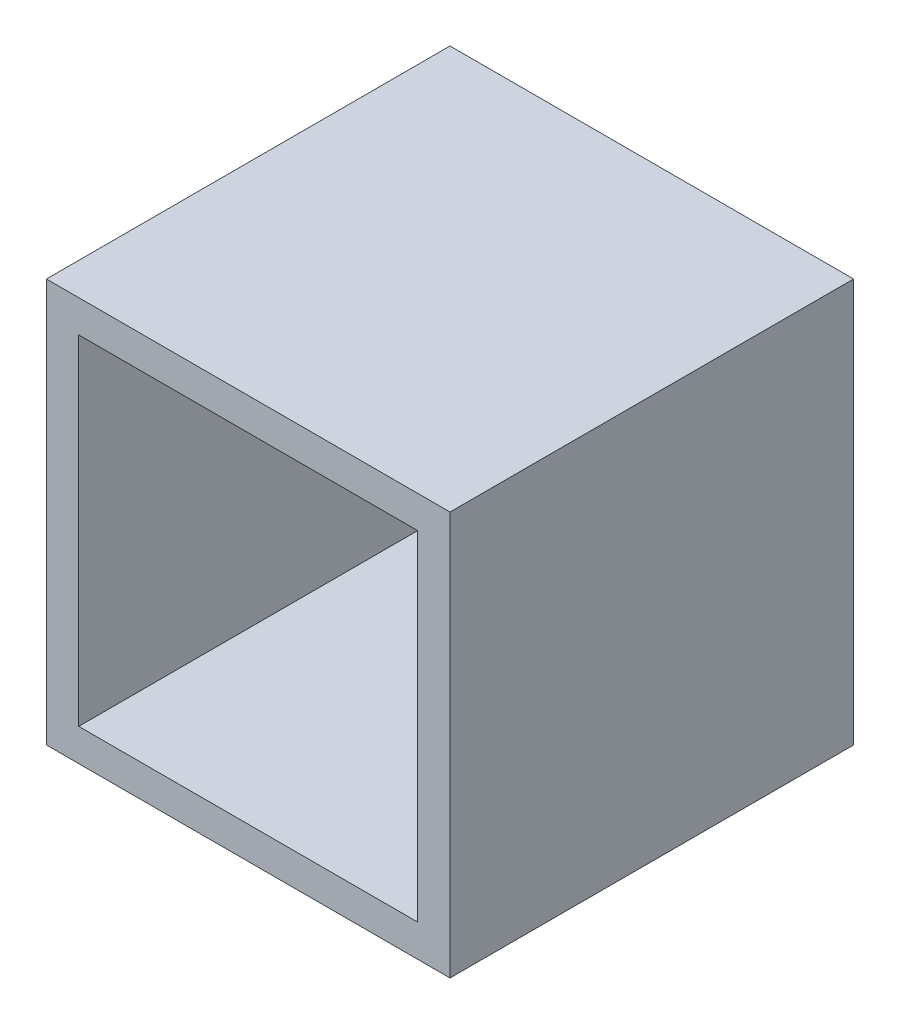
from build123d import *

# Parameters (mm, degrees)
SKETCH1_W           = 10
SKETCH1_H           = 10
BOSS_EXTRUDE1_DEPTH = 0.8
SKETCH2_W           = 10
SKETCH2_H           = 10
SKETCH2_W_2         = 8.4
SKETCH2_H_2         = 8.4
BOSS_EXTRUDE2_DEPTH = 9.2


with BuildPart() as part:
    # Sketch1 → Boss-Extrude1 (new body)
    with BuildSketch(Plane.XY):
        Rectangle(SKETCH1_W, SKETCH1_H)
    extrude(amount=BOSS_EXTRUDE1_DEPTH)

    # Sketch2 → Boss-Extrude2 (add)
    with BuildSketch(Plane.XY.offset(0.8)):
        Rectangle(SKETCH2_W, SKETCH2_H)
        Rectangle(SKETCH2_W_2, SKETCH2_H_2, mode=Mode.SUBTRACT)
    extrude(amount=BOSS_EXTRUDE2_DEPTH)


solid = part.part
